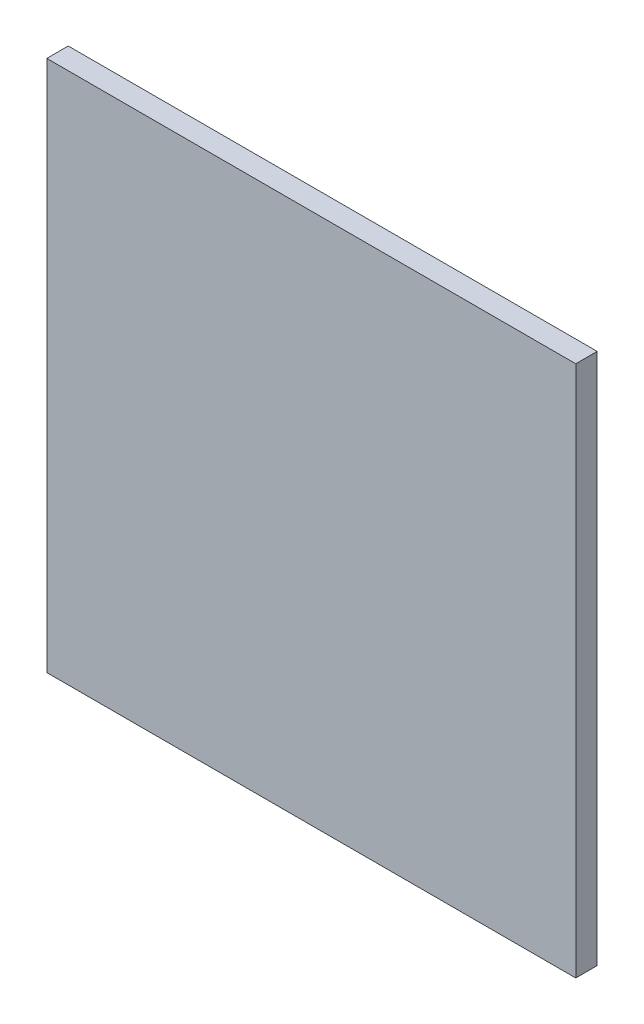
from build123d import *

# Parameters (mm, degrees)
SKETCH1_W           = 148
SKETCH1_H           = 148.834307206
BOSS_EXTRUDE1_DEPTH = 6


with BuildPart() as part:
    # Sketch1 → Boss-Extrude1 (new body)
    with BuildSketch(Plane.XY.offset(172.407141652)):
        with Locations((64.167049999, 165.363347507)):
            Rectangle(SKETCH1_W, SKETCH1_H)
    extrude(amount=BOSS_EXTRUDE1_DEPTH)


solid = part.part
